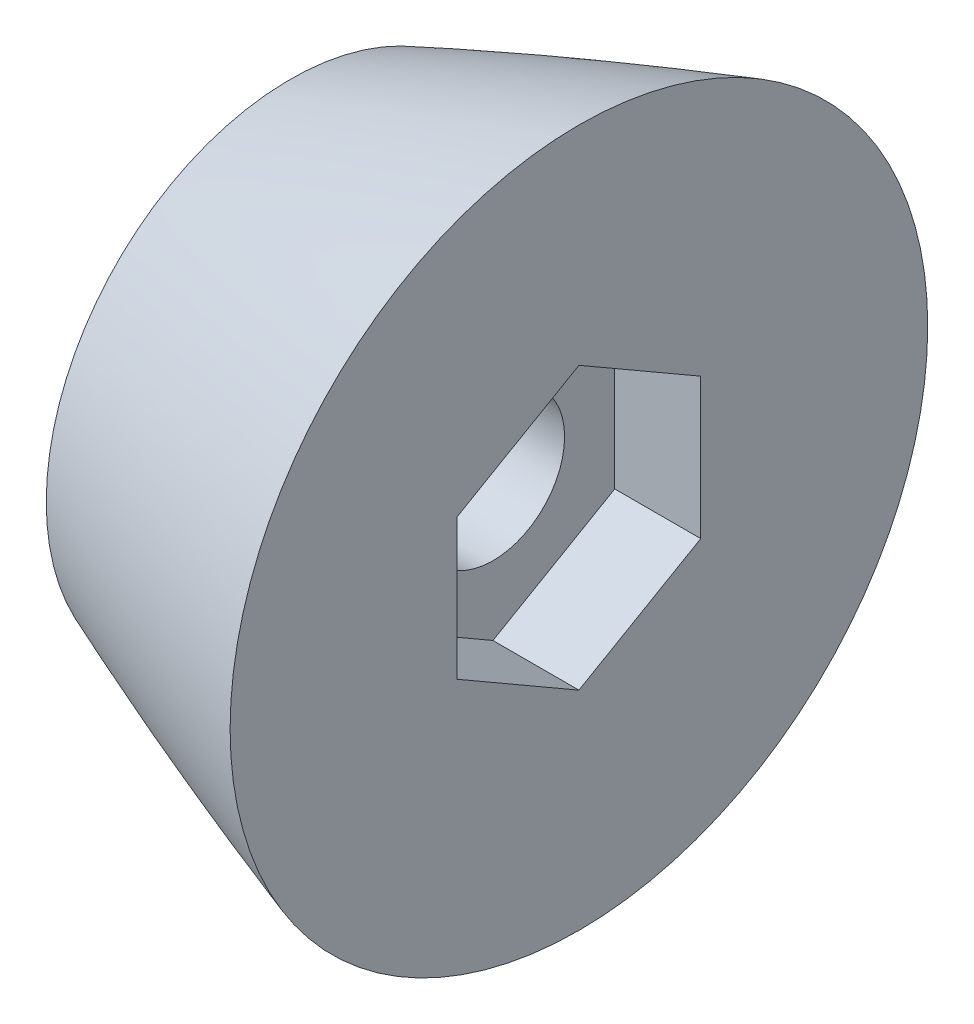
from build123d import *

# Parameters (mm, degrees)
SKIZZE4_R                            = 60
SCHNITT_LINEAR_AUSTRAGEN2_DEPTH      = 30
SKIZZE7_R                            = 100
SCHNITT_LINEAR_AUSTRAGEN4_DEPTH      = 270
SCHNITT_LINEAR_AUSTRAGEN3_DEPTH      = 20
SCHNITT_LINEAR_AUSTRAGEN3_DEPTH_BACK = 6
SKIZZE8_R                            = 5
SCHNITT_LINEAR_AUSTRAGEN5_DEPTH      = 15.138486988


with BuildPart() as part:
    # Skizze2 → Rotation1 (revolve)
    with BuildSketch(Plane.XY):
        with BuildLine():
            add(Edge.make_bspline(
                [(0, 0), (0.001795611, 0.01152954), (0.006532552, 0.034308256), (0.020814366, 0.078703922), (0.056576906, 0.164791889), (0.106248222, 0.260720398), (0.168831035, 0.366307006), (0.257283092, 0.501671411), (0.394318593, 0.693561073), (0.642308836, 1.002302903), (1.094138817, 1.494661034), (1.881119362, 2.241604858), (3.222990514, 3.351501836), (5.484884156, 4.977799832), (9.131242119, 7.255827512), (14.921132384, 10.401183749), (22.887129803, 14.153969102), (35.107137362, 19.201527382), (51.190688574, 24.887218377), (70.271426107, 30.664808891), (92.146031821, 36.297901472), (114.202164386, 41.163847082), (136.396259571, 45.35267271), (158.696515923, 48.929230891), (181.079729625, 51.941229812), (203.527006462, 54.42802234), (226.023091403, 56.423318789), (248.554958993, 57.959192165), (271.111661384, 59.068213328), (291.830400074, 59.728200821), (306.910887079, 60.003248255), (316.347321901, 60.107131137), (320.138486888, 60.138935837)],
                knots=[0, 0, 0, 0, 0, 0.000129466, 0.000258932, 0.000517865, 0.001035729, 0.001329598, 0.001623466, 0.002316092, 0.003657337, 0.005731188, 0.00905026, 0.014374967, 0.023011204, 0.036694212, 0.056839005, 0.087619321, 0.120902055, 0.183694742, 0.246487462, 0.309280168, 0.372072878, 0.43486559, 0.497658301, 0.560451012, 0.623243722, 0.686036437, 0.748829149, 0.811621861, 0.874414574, 0.916582404, 0.916582404, 0.916582404, 0.916582404, 0.916582404], degree=4))
            Line((0, 0), (320.138486888, 0))
            Line((320.138486888, 0), (320.138486888, 60.138935837))
        make_face()
    revolve(axis=Axis((0, 0, 0), (1, 0, 0)))

    # Skizze4 → Schnitt-Linear austragen2 (cut)
    with BuildSketch(Plane(origin=(0, 0, 0), x_dir=(0, 0, -1), z_dir=(1, 0, 0))):
        Circle(SKIZZE4_R)
    extrude(amount=SCHNITT_LINEAR_AUSTRAGEN2_DEPTH, mode=Mode.SUBTRACT)

    # Skizze7 → Schnitt-Linear austragen4 (cut)
    with BuildSketch(Plane(origin=(320.138486888, 0, 0), x_dir=(0, 0, -1), z_dir=(1, 0, 0))):
        Circle(SKIZZE7_R)
    extrude(amount=-SCHNITT_LINEAR_AUSTRAGEN4_DEPTH, mode=Mode.SUBTRACT)

    # Skizze6 → Schnitt-Linear austragen3 (cut, two sides)
    with BuildSketch(Plane(origin=(50.138486888, 0, 0), x_dir=(0, 0, -1), z_dir=(1, 0, 0))) as schnitt_linear_austragen3_sk:
        Polygon((0, -9.814954576), (8.5, -4.907477288), (8.5, 4.907477288), (0, 9.814954576), (-8.5, 4.907477288), (-8.5, -4.907477288), align=None)
    extrude(amount=SCHNITT_LINEAR_AUSTRAGEN3_DEPTH, mode=Mode.SUBTRACT)
    extrude(schnitt_linear_austragen3_sk.sketch, amount=-SCHNITT_LINEAR_AUSTRAGEN3_DEPTH_BACK, mode=Mode.SUBTRACT)

    # Skizze8 → Schnitt-Linear austragen5 (cut, through all)
    with BuildSketch(Plane(origin=(44.138486888, 0, 0), x_dir=(0, 0, -1), z_dir=(1, 0, 0))):
        Circle(SKIZZE8_R)
    extrude(amount=-SCHNITT_LINEAR_AUSTRAGEN5_DEPTH, mode=Mode.SUBTRACT)


solid = part.part
